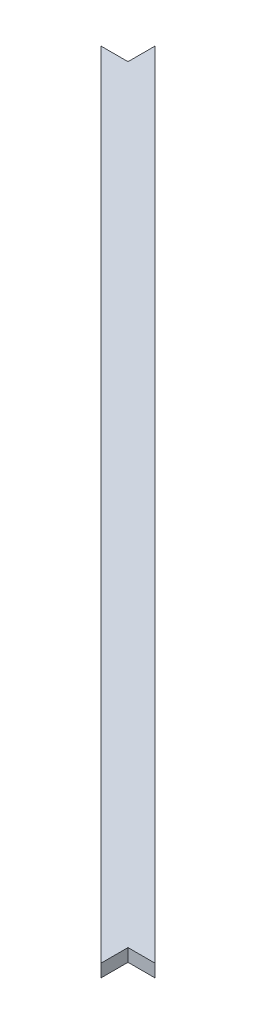
from build123d import *

# Parameters (mm, degrees)
BOSS_EXTRUDE1_DEPTH = 12.7


with BuildPart() as part:
    # Sketch1 → Boss-Extrude1 (new body)
    with BuildSketch(Plane(origin=(0, 0, 0), x_dir=(1, 0, 0), z_dir=(0, 1, 0))):
        Polygon((-380.95, 407.890768363), (-380.95, 380.95), (-407.890768363, 380.95), (380.95, -407.890768363), (380.95, -380.95), (407.890768363, -380.95), align=None)
    extrude(amount=BOSS_EXTRUDE1_DEPTH)


solid = part.part
